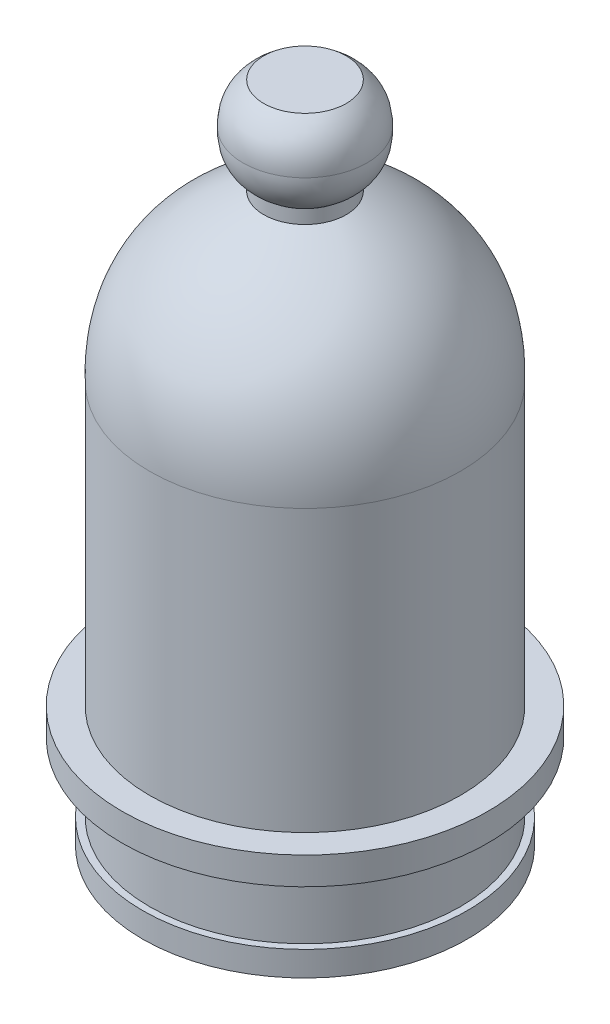
from build123d import *

# Parameters (mm, degrees)
SKETCH1_R           = 11.8
BOSS_EXTRUDE1_DEPTH = 1.8
SKETCH2_R           = 11.3
BOSS_EXTRUDE2_DEPTH = 5
SKETCH3_R           = 13.3
BOSS_EXTRUDE3_DEPTH = 2
SKETCH4_R           = 11.3
BOSS_EXTRUDE4_DEPTH = 20.4
SKETCH6_R           = 3
BOSS_EXTRUDE5_DEPTH = 1


with BuildPart() as part:
    # Sketch1 → Boss-Extrude1 (new body)
    with BuildSketch(Plane(origin=(0, 0, 0), x_dir=(1, 0, 0), z_dir=(0, 1, 0))):
        Circle(SKETCH1_R)
    extrude(amount=BOSS_EXTRUDE1_DEPTH)

    # Sketch2 → Boss-Extrude2 (add)
    with BuildSketch(Plane(origin=(0, 1.8, 0), x_dir=(1, 0, 0), z_dir=(0, 1, 0))):
        Circle(SKETCH2_R)
    extrude(amount=BOSS_EXTRUDE2_DEPTH)

    # Sketch3 → Boss-Extrude3 (add)
    with BuildSketch(Plane(origin=(0, 6.8, 0), x_dir=(1, 0, 0), z_dir=(0, 1, 0))):
        Circle(SKETCH3_R)
    extrude(amount=BOSS_EXTRUDE3_DEPTH)

    # Sketch4 → Boss-Extrude4 (add)
    with BuildSketch(Plane(origin=(0, 8.8, 0), x_dir=(1, 0, 0), z_dir=(0, 1, 0))):
        Circle(SKETCH4_R)
    extrude(amount=BOSS_EXTRUDE4_DEPTH)

    # Sketch5 → Revolve1 (revolve)
    with BuildSketch(Plane(origin=(0, 0, 0), x_dir=(0, 0, -1), z_dir=(1, 0, 0))):
        with BuildLine():
            add(Edge.make_bspline(
                [(-10.5, 34.2), (-8.718155673, 38.74792404), (-3, 41.2)],
                knots=[0.330462847, 0.330462847, 0.330462847, 1, 1, 1], degree=2))
            Line((-10.5, 34.2), (0, 34.2))
            Line((0, 34.2), (0, 41.2))
            Line((0, 41.2), (-3, 41.2))
        make_face()
        with BuildLine():
            add(Edge.make_bspline(
                [(-11.3, 29.2), (-11.379463292, 31.955285248), (-10.5, 34.2)],
                knots=[0, 0, 0, 0.330462847, 0.330462847, 0.330462847], degree=2))
            Line((-11.3, 29.2), (0, 29.2))
            Line((0, 29.2), (0, 34.2))
            Line((0, 34.2), (-10.5, 34.2))
        make_face()
    revolve(axis=Axis((0, 29.2, 0), (0, 1, 0)))

    # Sketch6 → Boss-Extrude5 (add)
    with BuildSketch(Plane(origin=(0, 41.2, 0), x_dir=(1, 0, 0), z_dir=(0, 1, 0))):
        Circle(SKETCH6_R)
    extrude(amount=BOSS_EXTRUDE5_DEPTH)

    # Sketch7 → Revolve2 (revolve)
    with BuildSketch(Plane(origin=(0, 0, 0), x_dir=(0, 0, -1), z_dir=(1, 0, 0))):
        with BuildLine():
            Line((-4.25, 43.7), (0, 43.7))
            Line((0, 43.7), (0, 45.2))
            Line((0, 45.2), (-4.5, 45.2))
            add(Edge.make_bspline(
                [(-4.25, 43.7), (-4.53338952, 44.377370072), (-4.5, 45.2)],
                knots=[0.56217108, 0.56217108, 0.56217108, 1, 1, 1], degree=2))
        make_face()
        with BuildLine():
            Line((-3, 42.2), (0, 42.2))
            Line((0, 42.2), (0, 43.7))
            Line((0, 43.7), (-4.25, 43.7))
            add(Edge.make_bspline(
                [(-3, 42.2), (-3.886128668, 42.830258767), (-4.25, 43.7)],
                knots=[0, 0, 0, 0.56217108, 0.56217108, 0.56217108], degree=2))
        make_face()
    revolve2 = revolve(axis=Axis((0, 42.2, 0), (0, 1, 0)))

    # Mirror1: Revolve2 across plane
    add(revolve2.mirror(Plane(origin=(0, 45.2, 0), x_dir=(0, 0, 1), z_dir=(0, -1, 0))))


solid = part.part
